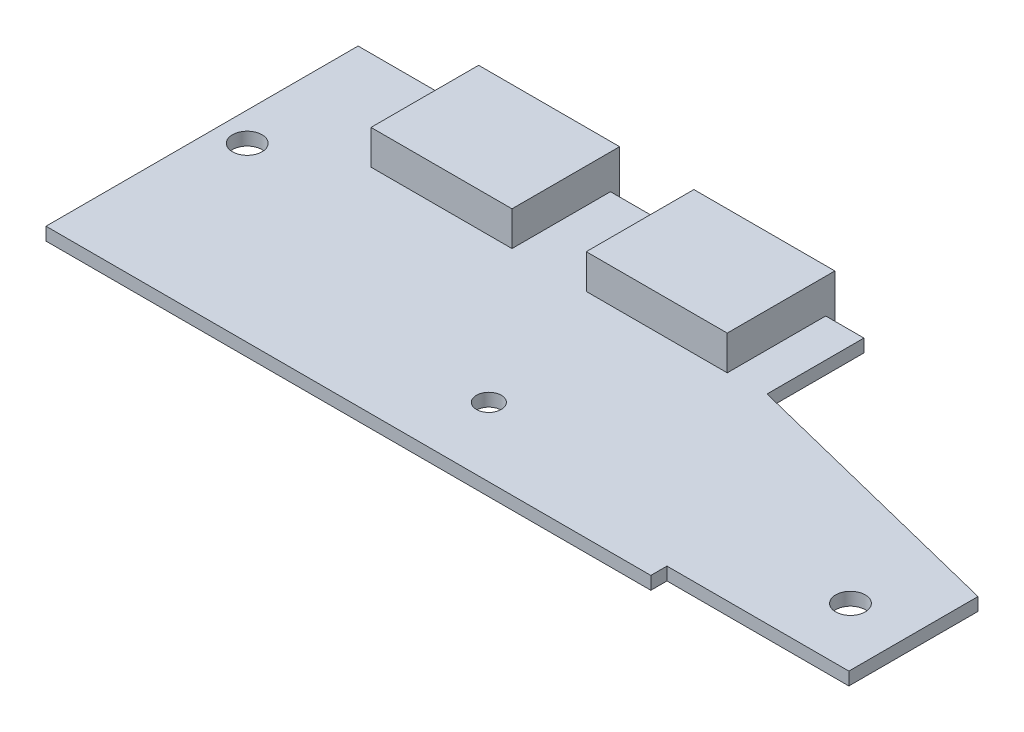
from build123d import *

# Parameters (mm, degrees)
EXTRUDE_1_DEPTH      = 1.2
SKETCH_2_R           = 1.375
SKETCH_2_R_2         = 1.15
CUT_EXTRUDE_1_DEPTH  = 2.2
SKETCH_3_W           = 13.1
SKETCH_3_H           = 10
EXTRUDE_2_DEPTH      = 3.2
EXTRUDE_2_DEPTH_BACK = 2.5
SKETCH_4_W           = 5.3
SKETCH_4_H           = 5.3
EXTRUDE_3_DEPTH      = 5.5


with BuildPart() as part:
    # Эскиз1 → Бобышка-Вытянуть1 (new body)
    with BuildSketch(Plane(origin=(0, 0, 0), x_dir=(1, 0, 0), z_dir=(0, 1, 0))):
        Polygon((0, 0), (0, 29), (47, 29), (47, 20), (73.1, 13.5), (73.1, 1.5), (56.2, 1.5), (56.2, 0), align=None)
    extrude(amount=EXTRUDE_1_DEPTH)

    # Эскиз2 → Вырез-Вытянуть1 (cut, through all)
    with BuildSketch(Plane(origin=(0, 1.2, 0), x_dir=(1, 0, 0), z_dir=(0, 1, 0))):
        with Locations((2.675, 16.025)):
            Circle(SKETCH_2_R)
        with Locations((67.725, 7.025)):
            Circle(SKETCH_2_R)
        with Locations((34.75, 6.4)):
            Circle(SKETCH_2_R_2)
    extrude(amount=-CUT_EXTRUDE_1_DEPTH, mode=Mode.SUBTRACT)

    # Эскиз3 → Бобышка-Вытянуть2 (add, two sides)
    with BuildSketch(Plane(origin=(0, 1.2, 0), x_dir=(1, 0, 0), z_dir=(0, 1, 0))) as extrude_2_sk:
        with Locations((16.9, 24.85)):
            Rectangle(SKETCH_3_W, SKETCH_3_H)
        with Locations((36.9, 24.85)):
            Rectangle(SKETCH_3_W, SKETCH_3_H)
    extrude(amount=EXTRUDE_2_DEPTH)
    extrude(extrude_2_sk.sketch, amount=-EXTRUDE_2_DEPTH_BACK)

    # Эскиз4 → Бобышка-Вытянуть3 (add)
    with BuildSketch(Plane.XZ):
        with Locations((18.15, -8.15)):
            Rectangle(SKETCH_4_W, SKETCH_4_H)
    extrude(amount=EXTRUDE_3_DEPTH)


solid = part.part
